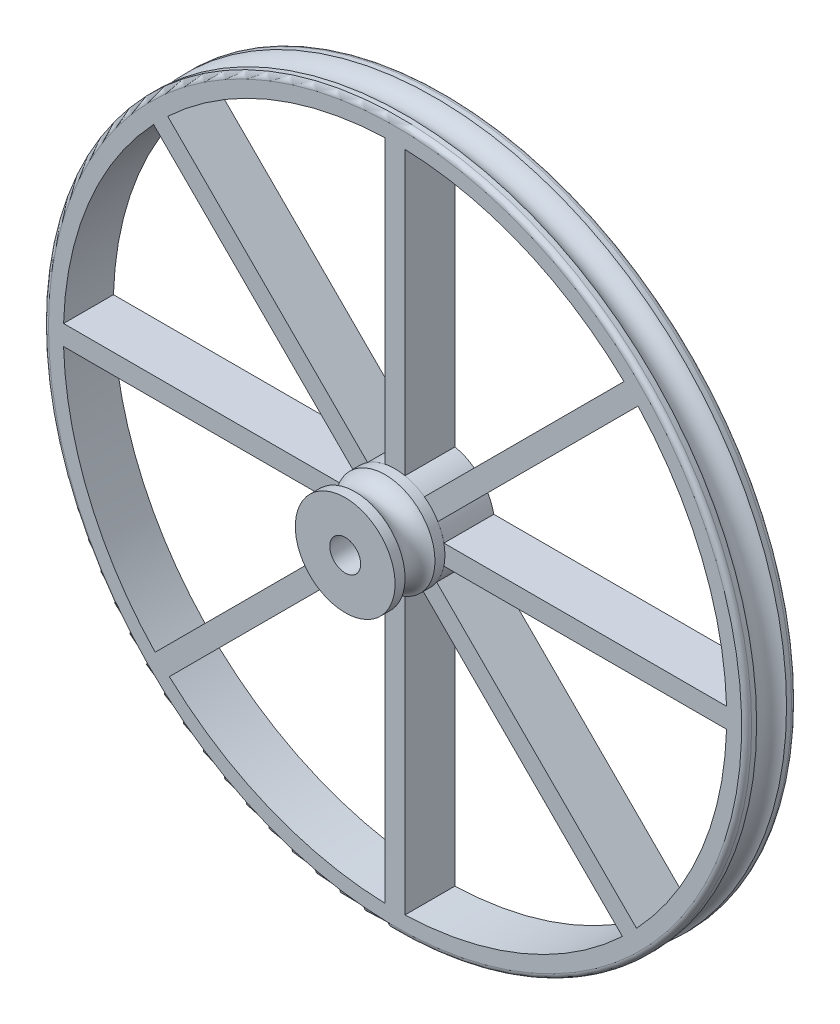
from build123d import *

# Parameters (mm, degrees)
SKETCH7_R          = 1.55
CUT_EXTRUDE1_DEPTH = 10
CUT_EXTRUDE2_DEPTH = 5
FILLET1_R          = 0.5


with BuildPart() as part:
    # Sketch4 → Revolve1 (revolve)
    with BuildSketch(Plane(origin=(0, 0, 0), x_dir=(0, 0, -1), z_dir=(1, 0, 0))):
        with BuildLine():
            Line((-5, 35.25), (-4, 35.25))
            ThreePointArc((-4, 35.25), (-2.5, 34.25), (-1, 35.25))
            Line((-1, 35.25), (0, 35.25))
            Line((0, 35.25), (0, 0))
            Line((0, 0), (-5, 0))
            Line((-5, 0), (-5, 35.25))
        make_face()
    revolve(axis=Axis((0, 0, 5), (0, 0, -1)))


with BuildPart() as body_2:
    # Sketch6 → Revolve2 (revolve)
    with BuildSketch(Plane(origin=(0, 0, 0), x_dir=(0, 0, -1), z_dir=(1, 0, 0))):
        with BuildLine():
            Line((-5, 0), (-5, 5))
            Line((-5, 5), (-6, 5))
            ThreePointArc((-6, 5), (-7.5, 4), (-9, 5))
            Line((-9, 5), (-10, 5))
            Line((-10, 5), (-10, 0))
            Line((-10, 0), (-5, 0))
        make_face()
    revolve(axis=Axis((0, 0, 10), (0, 0, -1)))


with BuildPart() as cut_extrude1_tool:
    # Sketch7 → Cut-Extrude1 (new body)
    with BuildSketch(Plane.XY):
        Circle(SKETCH7_R)
    extrude(amount=CUT_EXTRUDE1_DEPTH)


with BuildPart() as part_1:
    add(part.part)

    # Cut-Extrude1: cut by cut_extrude1_tool
    add(cut_extrude1_tool.part, mode=Mode.SUBTRACT)

    # Sketch8 → Cut-Extrude2 (cut)
    with BuildSketch(Plane.XY):
        with BuildLine():
            Line((4.898979486, 1), (33.234959004, 1))
            ThreePointArc((33.234959004, 1), (30.761315315, 12.621568051), (24.359467637, 22.631368418))
            Line((24.359467637, 22.631368418), (4.29237548, 2.564276261))
            ThreePointArc((4.29237548, 2.564276261), (4.661758421, 1.807763375), (4.898979486, 1))
        make_face()
        with BuildLine():
            Line((1, 4.898979486), (1, 33.234959004))
            ThreePointArc((1, 33.234959004), (12.826717716, 30.676339622), (22.954698728, 24.055026633))
            Line((22.954698728, 24.055026633), (2.942302171, 4.042630076))
            ThreePointArc((2.942302171, 4.042630076), (2.017119277, 4.5750661), (1, 4.898979486))
        make_face()
        with BuildLine():
            Line((4.898979486, -1), (33.234959004, -1))
            ThreePointArc((33.234959004, -1), (30.718994456, -12.724224126), (24.207771665, -22.793558103))
            Line((24.207771665, -22.793558103), (4.171208396, -2.756994834))
            ThreePointArc((4.171208396, -2.756994834), (4.619397663, -1.913417162), (4.898979486, -1))
        make_face()
        with BuildLine():
            Line((1, -4.898979486), (1, -33.234959004))
            ThreePointArc((1, -33.234959004), (12.724224126, -30.718994456), (22.793558103, -24.207771665))
            Line((22.793558103, -24.207771665), (2.756994834, -4.171208396))
            ThreePointArc((2.756994834, -4.171208396), (1.913417162, -4.619397663), (1, -4.898979486))
        make_face()
        with BuildLine():
            Line((-1, -33.234959004), (-1, -4.898979486))
            ThreePointArc((-1, -4.898979486), (-1.807763375, -4.661758421), (-2.564276261, -4.29237548))
            Line((-2.564276261, -4.29237548), (-22.631368418, -24.359467637))
            ThreePointArc((-22.631368418, -24.359467637), (-12.621568051, -30.761315315), (-1, -33.234959004))
        make_face()
        with BuildLine():
            Line((-33.234959004, -1), (-4.898979486, -1))
            ThreePointArc((-4.898979486, -1), (-4.5750661, -2.017119277), (-4.042630076, -2.942302171))
            Line((-4.042630076, -2.942302171), (-24.055026633, -22.954698728))
            ThreePointArc((-24.055026633, -22.954698728), (-30.676339622, -12.826717716), (-33.234959004, -1))
        make_face()
        with BuildLine():
            Line((-33.234959004, 1), (-4.898979486, 1))
            ThreePointArc((-4.898979486, 1), (-4.619397663, 1.913417162), (-4.171208396, 2.756994834))
            Line((-4.171208396, 2.756994834), (-24.207771665, 22.793558103))
            ThreePointArc((-24.207771665, 22.793558103), (-30.718994456, 12.724224126), (-33.234959004, 1))
        make_face()
        with BuildLine():
            Line((-1, 4.898979486), (-1, 33.234959004))
            ThreePointArc((-1, 33.234959004), (-12.724224126, 30.718994456), (-22.793558103, 24.207771665))
            Line((-22.793558103, 24.207771665), (-2.756994834, 4.171208396))
            ThreePointArc((-2.756994834, 4.171208396), (-1.913417162, 4.619397663), (-1, 4.898979486))
        make_face()
    extrude(amount=CUT_EXTRUDE2_DEPTH, mode=Mode.SUBTRACT)

    # Fillet1
    fillet1_edges = [part_1.edges().sort_by_distance(p)[0] for p in [
        (0, -35.25, 5),
        (0, -35.25, 0),
    ]]
    fillet(fillet1_edges, radius=FILLET1_R)


with BuildPart() as body_2_1:
    add(body_2.part)

    # Cut-Extrude1: cut by cut_extrude1_tool
    add(cut_extrude1_tool.part, mode=Mode.SUBTRACT)


solid = Compound([part_1.part, body_2_1.part])
